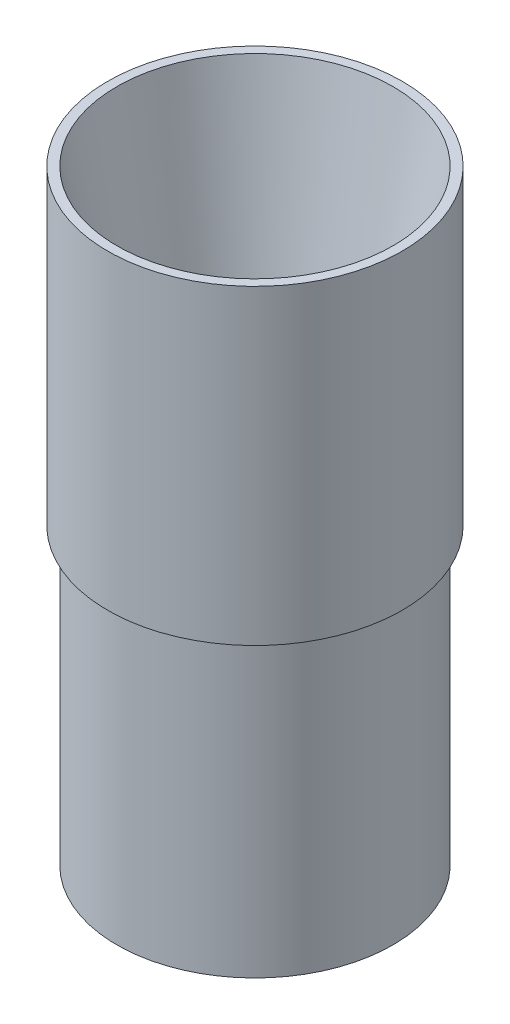
from build123d import *


with BuildPart() as part:
    # Sketch1 → Revolve1 (revolve)
    with BuildSketch(Plane.XY):
        Polygon((24.2189, 0), (47.625, 132.742589398), (50.8, 132.742589398), (50.8, 25.4), (47.625, 25.4), (47.625, -76.2), (41.275, -76.2), (41.275, 0), align=None)
    revolve(axis=Axis((0, 0, 0), (0, 1, 0)))


solid = part.part
